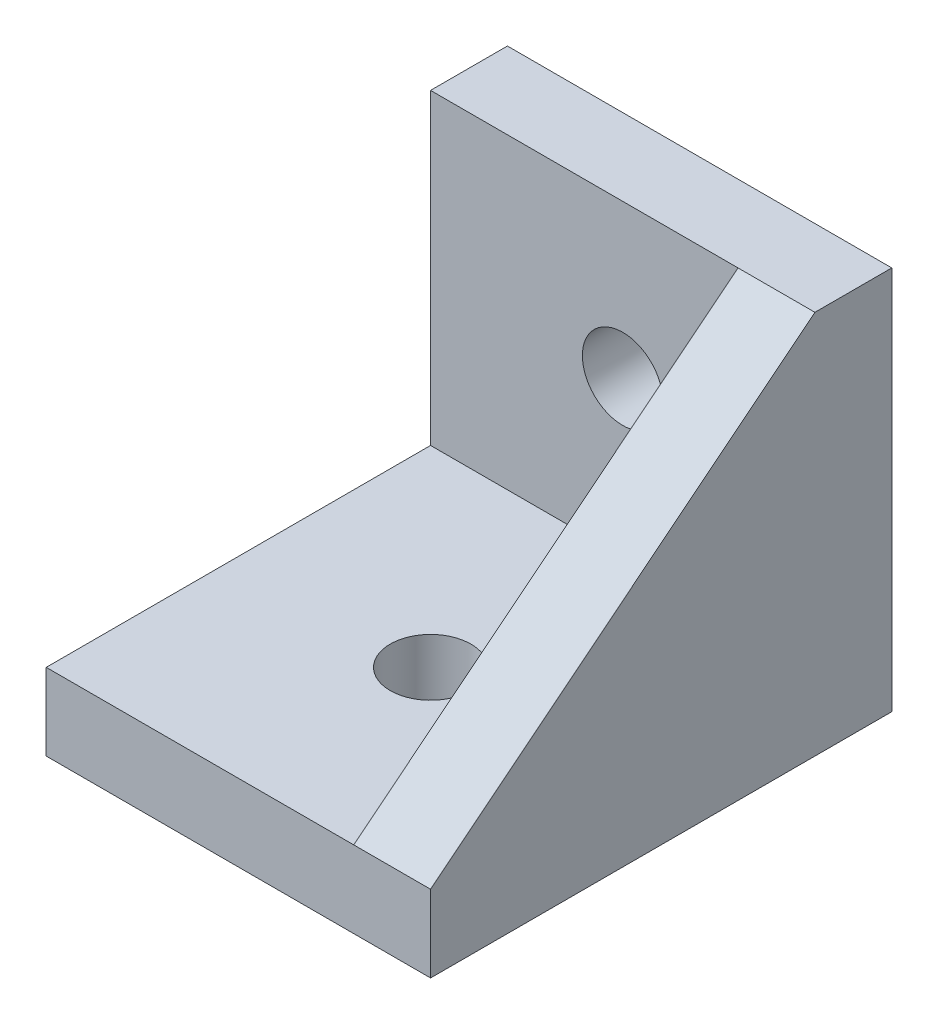
from build123d import *

# Parameters (mm, degrees)
BASE_PROFILE_SKETCH_W          = 12.001239904
BASE_PROFILE_SKETCH_H          = 15.00124
BASE_PROFILE_EXTRUDE_DEPTH     = 3
BACK_PROFILE_SKETCH_W          = 12.001239904
BACK_PROFILE_SKETCH_H          = 3
BACK_PROFILE_EXTRUDE_DEPTH     = 15
SIDE_PROFILE_EXTRUDE_DEPTH     = 3
BOTTOM_MOUNTING_HOLE_CUT_REACH = 5
BOTTOM_MOUNTING_HOLE_SKETCH_R  = 1.575
BACK_MOUNTING_HOLE_CUT_REACH   = 5
BACK_MOUNTING_HOLE_SKETCH_R    = 1.575


with BuildPart() as part:
    # Base Profile Sketch → Base Profile Extrude (new body)
    with BuildSketch(Plane.XY):
        Rectangle(BASE_PROFILE_SKETCH_W, BASE_PROFILE_SKETCH_H)
    extrude(amount=BASE_PROFILE_EXTRUDE_DEPTH)

    # Back Profile Sketch → Back Profile Extrude (add)
    with BuildSketch(Plane.XY.offset(3)):
        with Locations((0, -6.00062)):
            Rectangle(BACK_PROFILE_SKETCH_W, BACK_PROFILE_SKETCH_H)
    extrude(amount=BACK_PROFILE_EXTRUDE_DEPTH)

    # Side Profile Sketch → Side Profile Extrude (add)
    with BuildSketch(Plane(origin=(6.000619952, 0, 0), x_dir=(0, 0, -1), z_dir=(1, 0, 0))):
        Polygon((0, -7.50062), (0, 7.50062), (-3, 7.50062), (-18, -4.50062), (-18, -7.50062), align=None)
    extrude(amount=SIDE_PROFILE_EXTRUDE_DEPTH)

    # Bottom Mounting Hole Sketch → Bottom Mounting Hole Cut (cut, up to next)
    with BuildSketch(Plane.XY.offset(3), mode=Mode.PRIVATE) as bottom_mounting_hole_cut_sk1:
        with Locations((1.5, 1.5)):
            Circle(BOTTOM_MOUNTING_HOLE_SKETCH_R)
    bottom_mounting_hole_cut_tool1 = extrude(bottom_mounting_hole_cut_sk1.sketch, amount=-BOTTOM_MOUNTING_HOLE_CUT_REACH, mode=Mode.PRIVATE) & part.part
    add(bottom_mounting_hole_cut_tool1.solids().sort_by_distance((1.5, 1.5, 3))[0], mode=Mode.SUBTRACT)

    # Back Mounting Hole Sketch → Back Mounting Hole Cut (cut, up to next)
    with BuildSketch(Plane(origin=(0, -4.50062, 0), x_dir=(1, 0, 0), z_dir=(0, 1, 0)), mode=Mode.PRIVATE) as back_mounting_hole_cut_sk1:
        with Locations((1.5, -10.5)):
            Circle(BACK_MOUNTING_HOLE_SKETCH_R)
    back_mounting_hole_cut_tool1 = extrude(back_mounting_hole_cut_sk1.sketch, amount=-BACK_MOUNTING_HOLE_CUT_REACH, mode=Mode.PRIVATE) & part.part
    add(back_mounting_hole_cut_tool1.solids().sort_by_distance((1.5, -4.50062, 10.5))[0], mode=Mode.SUBTRACT)


solid = part.part
